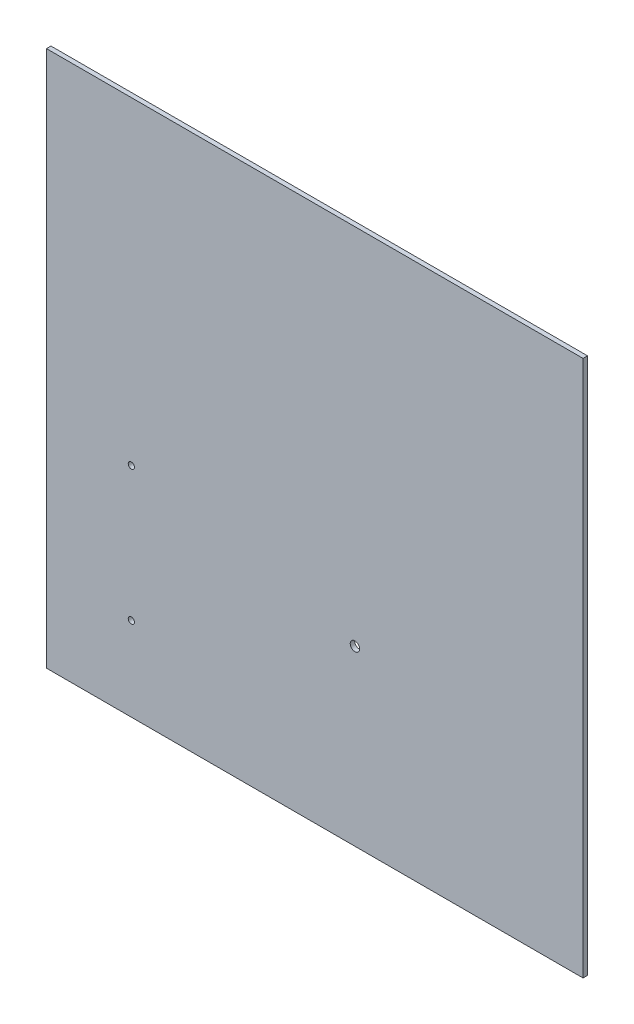
from build123d import *

# Parameters (mm, degrees)
SKETCH1_W               = 304.8
SKETCH1_H               = 304.8
BOSS_EXTRUDE1_DEPTH     = 2.54
SKETCH2_R               = 1.7526
SKETCH2_R_2             = 2.667
CUT_EXTRUDE1_DEPTH      = 1
CUT_EXTRUDE1_DEPTH_BACK = 3.54


with BuildPart() as part:
    # Sketch1 → Boss-Extrude1 (new body)
    with BuildSketch(Plane.XY):
        with Locations((152.4, 152.4)):
            Rectangle(SKETCH1_W, SKETCH1_H)
    extrude(amount=BOSS_EXTRUDE1_DEPTH)

    # Sketch2 → Cut-Extrude1 (cut, two sides)
    with BuildSketch(Plane.XY.offset(2.54)) as cut_extrude1_sk:
        with Locations((48.204991745, 47.589666893)):
            Circle(SKETCH2_R)
        with Locations((175.204991745, 98.389666893)):
            Circle(SKETCH2_R_2)
        with Locations((48.204991745, 123.789666893)):
            Circle(SKETCH2_R)
    extrude(amount=CUT_EXTRUDE1_DEPTH, mode=Mode.SUBTRACT)
    extrude(cut_extrude1_sk.sketch, amount=-CUT_EXTRUDE1_DEPTH_BACK, mode=Mode.SUBTRACT)


solid = part.part
